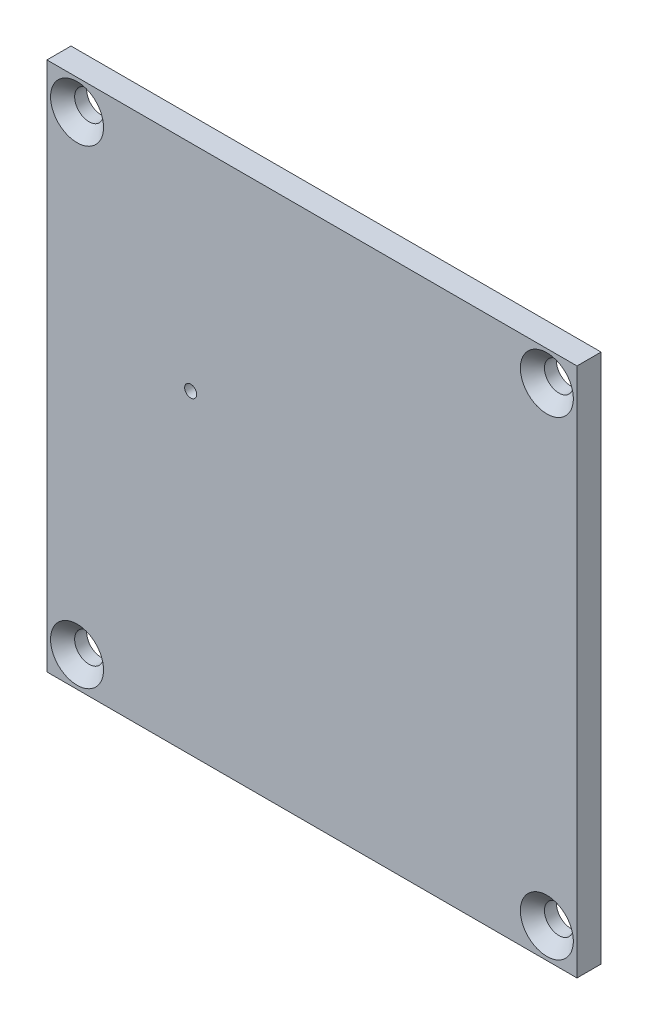
from build123d import *

# Parameters (mm, degrees)
ESQUISSE3_W                                 = 44
ESQUISSE3_H                                 = 44
BOSS_EXTRU_1_DEPTH                          = 2
SKETCH_HOLES_R                              = 0.5
CUT_EXTRUDE_HOLES_DEPTH                     = 3
FRAISAGE_POUR_VIS_T_TE_FRAIS_E_M21_AT_COUNT = 2
FRAISAGE_POUR_VIS_T_TE_FRAIS_E_M21_AT_PITCH = 39
FRAISAGE_POUR_VIS_T_TE_FRAIS_E_M21_2_COUNT  = 2
FRAISAGE_POUR_VIS_T_TE_FRAIS_E_M21_2_PITCH  = 55.154328933
FRAISAGE_POUR_VIS_T_TE_FRAIS_E_M21_3_COUNT  = 2
FRAISAGE_POUR_VIS_T_TE_FRAIS_E_M21_3_PITCH  = 39


with BuildPart() as part:
    # Esquisse3 → Boss.-Extru.1 (new body)
    with BuildSketch(Plane(origin=(0, 0, 0), x_dir=(0, 1, 0), z_dir=(0, 0, 1))):
        Rectangle(ESQUISSE3_W, ESQUISSE3_H)
    extrude(amount=BOSS_EXTRU_1_DEPTH)

    # Sketch_Holes → Cut_Extrude_Holes (cut, through all)
    with BuildSketch(Plane.XY.offset(2)):
        with Locations((-10.067654011, 4.160184375)):
            Circle(SKETCH_HOLES_R)
    extrude(amount=-CUT_EXTRUDE_HOLES_DEPTH, mode=Mode.SUBTRACT)

    # Esquisse5 → Fraisage pour vis à tête fraisée M21 (revolve, cut)
    with BuildSketch(Plane(origin=(19.5, -19.5, 2), x_dir=(0, -1, 0), z_dir=(1, 0, 0))):
        Polygon((0, 0), (0, 2), (1.2, 2), (1.2, 1), (2.2, 0), align=None)
    fraisage_pour_vis_t_te_frais_e_m21 = revolve(axis=Axis((19.5, -19.5, 8.35), (0, 0, -1)), mode=Mode.SUBTRACT)

    # Fraisage pour vis à tête fraisée M21 at: Fraisage pour vis à tête fraisée M21 ×2
    with Locations(*[(-i * FRAISAGE_POUR_VIS_T_TE_FRAIS_E_M21_AT_PITCH, 0, 0) for i in range(1, FRAISAGE_POUR_VIS_T_TE_FRAIS_E_M21_AT_COUNT)]):
        add(fraisage_pour_vis_t_te_frais_e_m21, mode=Mode.SUBTRACT)

    # Fraisage pour vis _ t_te frais_e M21 2: Fraisage pour vis à tête fraisée M21 ×2
    with Locations(*[Vector(-0.707106781, 0.707106781, 0) * (i * FRAISAGE_POUR_VIS_T_TE_FRAIS_E_M21_2_PITCH) for i in range(1, FRAISAGE_POUR_VIS_T_TE_FRAIS_E_M21_2_COUNT)]):
        add(fraisage_pour_vis_t_te_frais_e_m21, mode=Mode.SUBTRACT)

    # Fraisage pour vis _ t_te frais_e M21 3: Fraisage pour vis à tête fraisée M21 ×2
    with Locations(*[(0, i * FRAISAGE_POUR_VIS_T_TE_FRAIS_E_M21_3_PITCH, 0) for i in range(1, FRAISAGE_POUR_VIS_T_TE_FRAIS_E_M21_3_COUNT)]):
        add(fraisage_pour_vis_t_te_frais_e_m21, mode=Mode.SUBTRACT)


solid = part.part
